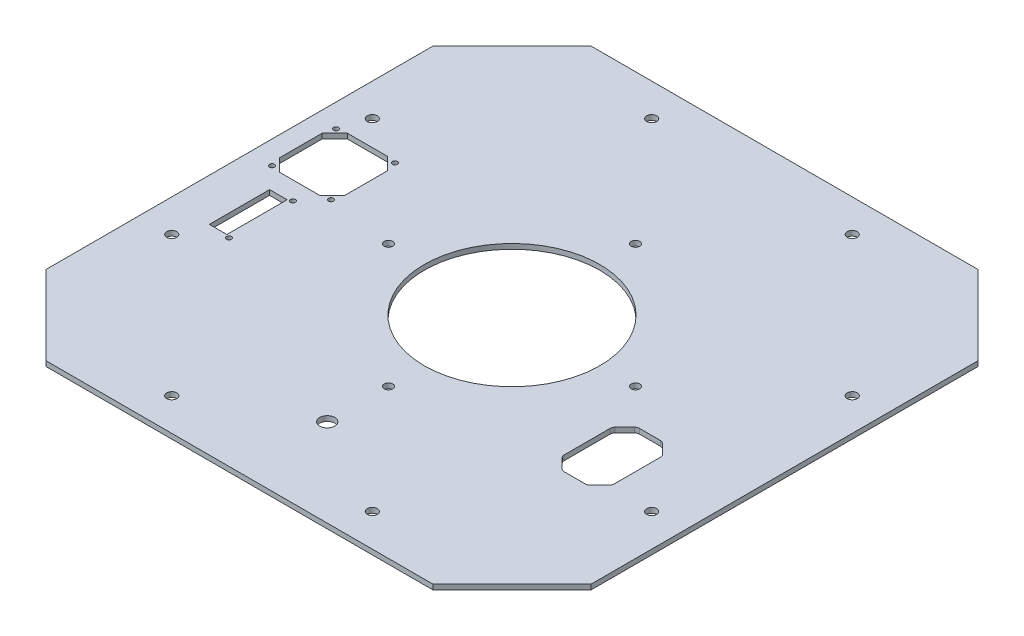
from build123d import *

# Parameters (mm, degrees)
SKETCH_1_R          = 2
EXTRUDE_1_DEPTH     = 2
SKETCH_2_R          = 1
SKETCH_2_R_2        = 1.7
SKETCH_2_R_3        = 35
SKETCH_2_R_4        = 3
SKETCH_2_W          = 7
SKETCH_2_H          = 24
CUT_EXTRUDE_1_DEPTH = 10


with BuildPart() as part:
    # 草图1 → 凸台-拉伸1 (new body)
    with BuildSketch(Plane(origin=(0, 0, 0), x_dir=(1, 0, 0), z_dir=(0, 1, 0))):
        Polygon((0, -9.790421162), (0, 144.54053128), (31.526911935, 176.067443214), (185.857864376, 176.067443214), (217.384776311, 144.54053128), (217.384776311, -9.790421162), (185.857864376, -41.317333096), (31.526911935, -41.317333096), align=None)
        with Locations((68.692388155, 163.08216184)):
            Circle(SKETCH_1_R, mode=Mode.SUBTRACT)
        with Locations((148.692388155, 163.08216184)):
            Circle(SKETCH_1_R, mode=Mode.SUBTRACT)
        with Locations((204.399494937, 107.375055059)):
            Circle(SKETCH_1_R, mode=Mode.SUBTRACT)
        with Locations((204.399494937, 27.375055059)):
            Circle(SKETCH_1_R, mode=Mode.SUBTRACT)
        with Locations((148.692388155, -28.332051722)):
            Circle(SKETCH_1_R, mode=Mode.SUBTRACT)
        with Locations((68.692388155, -28.332051722)):
            Circle(SKETCH_1_R, mode=Mode.SUBTRACT)
        with Locations((12.985281374, 27.375055059)):
            Circle(SKETCH_1_R, mode=Mode.SUBTRACT)
        with Locations((12.985281374, 107.375055059)):
            Circle(SKETCH_1_R, mode=Mode.SUBTRACT)
    extrude(amount=EXTRUDE_1_DEPTH)

    # 草图2 → 切除-拉伸1 (cut)
    with BuildSketch(Plane(origin=(0, 2, 0), x_dir=(1, 0, 0), z_dir=(0, 1, 0))):
        with Locations((9.25, 96.625055059)):
            Circle(SKETCH_2_R)
        with Locations((108.692388155, 116.625055059)):
            Circle(SKETCH_2_R_2)
        with Locations((108.692388155, 18.125055059)):
            Circle(SKETCH_2_R_2)
        with Locations((157.942388155, 67.375055059)):
            Circle(SKETCH_2_R_2)
        with Locations((59.442388155, 67.375055059)):
            Circle(SKETCH_2_R_2)
        with Locations((108.692388155, 67.375055059)):
            Circle(SKETCH_2_R_3)
        with Locations((32.75, 96.625055059)):
            Circle(SKETCH_2_R)
        with Locations((32.75, 71.125055059)):
            Circle(SKETCH_2_R)
        with Locations((9.25, 71.125055059)):
            Circle(SKETCH_2_R)
        with Locations((25.58, 63.125055059)):
            Circle(SKETCH_2_R)
        with Locations((25.58, 37.625055059)):
            Circle(SKETCH_2_R)
        with Locations((108.692388155, -6.317333096)):
            Circle(SKETCH_2_R_4)
        Polygon((29, 97.375055059), (34, 92.375055059), (34, 75.375055059), (29, 70.375055059), (13, 70.375055059), (8, 75.375055059), (8, 92.375055059), (13, 97.375055059), align=None)
        with Locations((20.5, 50.375055059)):
            Rectangle(SKETCH_2_W, SKETCH_2_H)
        with BuildLine():
            Line((173.213203436, 23.682666904), (181.556349186, 23.682666904))
            ThreePointArc((181.556349186, 23.682666904), (182.321716051, 23.834907839), (182.970562748, 24.268453341))
            Line((182.970562748, 24.268453341), (186.798989873, 28.096880466))
            ThreePointArc((186.798989873, 28.096880466), (187.232535376, 28.745727164), (187.384776311, 29.511094028))
            Line((187.384776311, 29.511094028), (187.384776311, 47.854239779))
            ThreePointArc((187.384776311, 47.854239779), (187.232535376, 48.619606644), (186.798989873, 49.268453341))
            Line((186.798989873, 49.268453341), (182.970562748, 53.096880466))
            ThreePointArc((182.970562748, 53.096880466), (182.321716051, 53.530425969), (181.556349186, 53.682666904))
            Line((181.556349186, 53.682666904), (173.213203436, 53.682666904))
            ThreePointArc((173.213203436, 53.682666904), (172.447836571, 53.530425969), (171.798989873, 53.096880466))
            Line((171.798989873, 53.096880466), (167.970562748, 49.268453341))
            ThreePointArc((167.970562748, 49.268453341), (167.537017246, 48.619606644), (167.384776311, 47.854239779))
            Line((167.384776311, 47.854239779), (167.384776311, 29.511094028))
            ThreePointArc((167.384776311, 29.511094028), (167.537017246, 28.745727164), (167.970562748, 28.096880466))
            Line((167.970562748, 28.096880466), (171.798989873, 24.268453341))
            ThreePointArc((171.798989873, 24.268453341), (172.447836571, 23.834907839), (173.213203436, 23.682666904))
        make_face()
    extrude(amount=-CUT_EXTRUDE_1_DEPTH, mode=Mode.SUBTRACT)


solid = part.part
